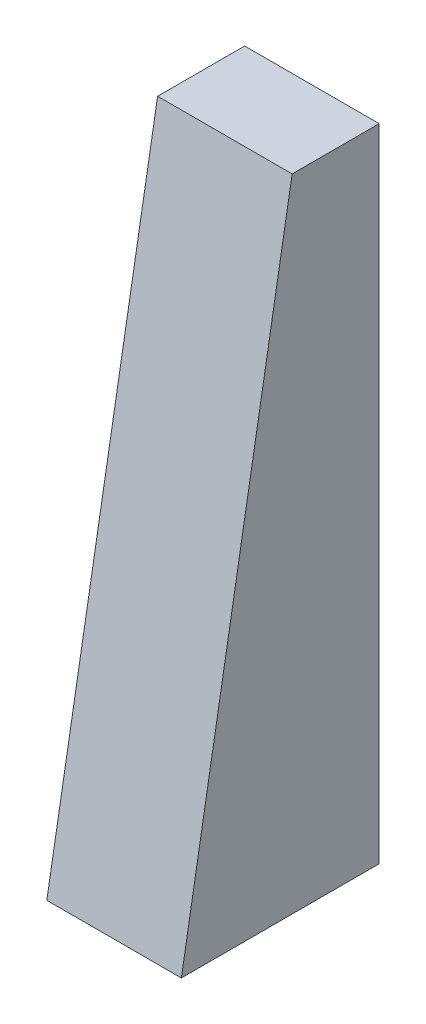
from build123d import *

# Parameters (mm, degrees)
BOSS_EXTRUDE1_DEPTH = 170


with BuildPart() as part:
    # Sketch1 → Boss-Extrude1 (new body)
    with BuildSketch(Plane(origin=(0, 0, 0), x_dir=(0, 0, -1), z_dir=(1, 0, 0))):
        Polygon((0, 0), (0, 810), (-110, 810), (-250, 0), align=None)
    extrude(amount=BOSS_EXTRUDE1_DEPTH)


solid = part.part
